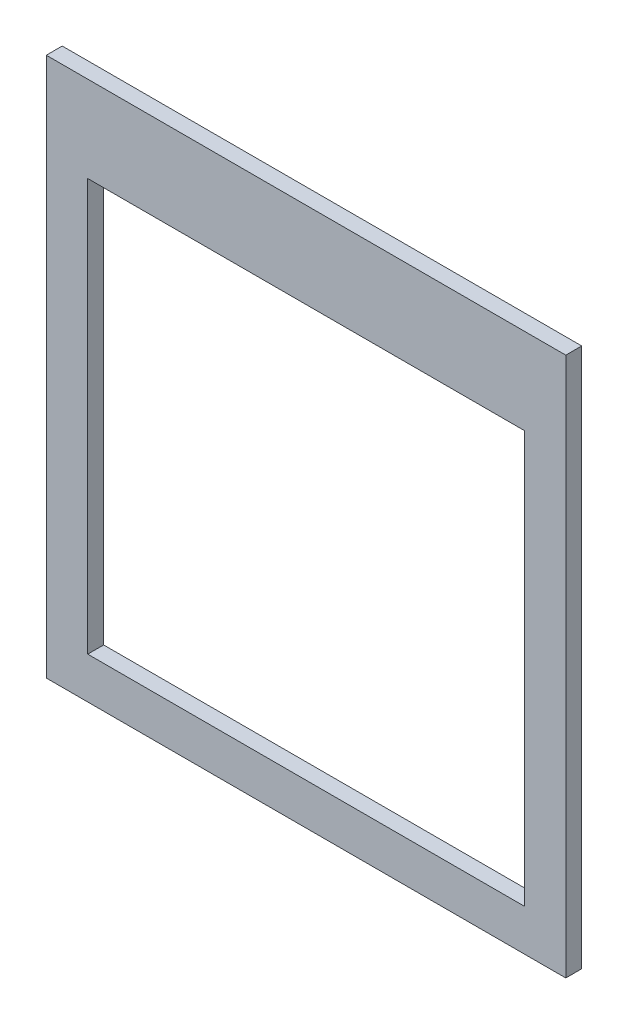
from build123d import *

# Parameters (mm, degrees)
SKETCH_1_W      = 326
SKETCH_1_H      = 338.5
SKETCH_1_W_2    = 274
SKETCH_1_H_2    = 258.5
EXTRUDE_1_DEPTH = 10


with BuildPart() as part:
    # Эскиз1 → Бобышка-Вытянуть1 (new body)
    with BuildSketch(Plane.XY):
        with Locations((140.228156891, -162.881320016)):
            Rectangle(SKETCH_1_W, SKETCH_1_H)
        with Locations((140.228156891, -176.881320016)):
            Rectangle(SKETCH_1_W_2, SKETCH_1_H_2, mode=Mode.SUBTRACT)
    extrude(amount=EXTRUDE_1_DEPTH)


solid = part.part
